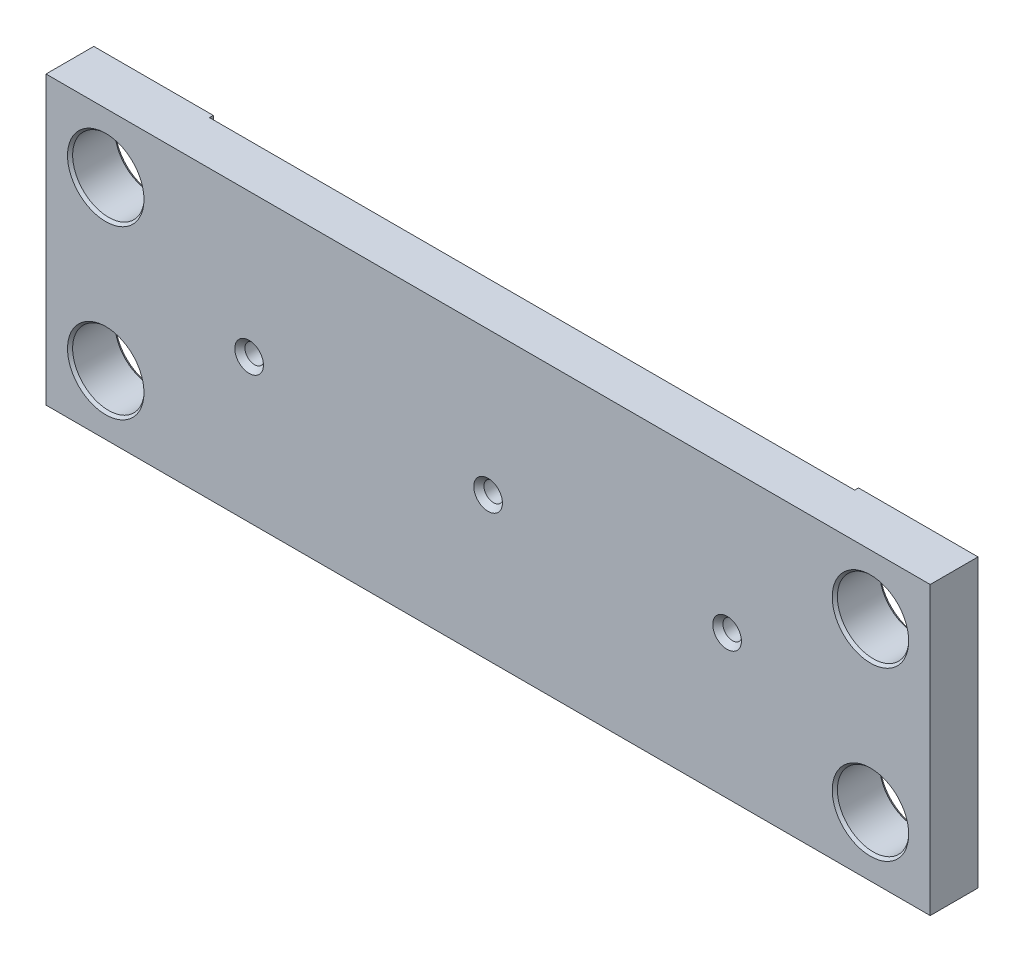
from build123d import *

# Parameters (mm, degrees)
SKETCH1_W                        = 234.95
SKETCH1_H                        = 76.2
EXTRUDE1_DEPTH                   = 12.7
F_1_2_CLEARANCE_HOLE1_AT_2_COUNT = 2
F_1_2_CLEARANCE_HOLE1_AT_2_PITCH = 44.45
F_1_2_CLEARANCE_HOLE1_AT_3_COUNT = 2
F_1_2_CLEARANCE_HOLE1_AT_3_PITCH = 203.2
F_1_2_CLEARANCE_HOLE1_AT_4_COUNT = 2
F_1_2_CLEARANCE_HOLE1_AT_4_PITCH = 208.004909798
SKETCH6_W                        = 171.45
SKETCH6_H                        = 76.2
CUT_EXTRUDE1_DEPTH               = 1.016
F_1_4_20_TAPPED_HOLE1_AT_2_COUNT = 2
F_1_4_20_TAPPED_HOLE1_AT_2_PITCH = 63.5
F_1_4_20_TAPPED_HOLE1_AT_3_COUNT = 2
F_1_4_20_TAPPED_HOLE1_AT_3_PITCH = 127


with BuildPart() as part:
    # Sketch1 → Extrude1 (new body)
    with BuildSketch(Plane.XY):
        Rectangle(SKETCH1_W, SKETCH1_H)
    extrude(amount=EXTRUDE1_DEPTH)

    # Sketch2 → 1/2 Clearance Hole1 (revolve, cut)
    with BuildSketch(Plane(origin=(-101.6, 22.225, 12.7), x_dir=(0, -1, 0), z_dir=(1, 0, 0))):
        Polygon((0, 0), (0, 12.7), (10.16, 12.7), (9.525, 11.969516061), (9.525, 0.730483939), (10.16, 0), align=None)
    f_1_2_clearance_hole1 = revolve(axis=Axis((-101.6, 22.225, 19.05), (0, 0, -1)), mode=Mode.SUBTRACT)

    # 1/2 Clearance Hole1 at 2: 1/2 Clearance Hole1 ×2
    with Locations(*[(0, -i * F_1_2_CLEARANCE_HOLE1_AT_2_PITCH, 0) for i in range(1, F_1_2_CLEARANCE_HOLE1_AT_2_COUNT)]):
        add(f_1_2_clearance_hole1, mode=Mode.SUBTRACT)

    # 1/2 Clearance Hole1 at 3: 1/2 Clearance Hole1 ×2
    with Locations(*[(i * F_1_2_CLEARANCE_HOLE1_AT_3_PITCH, 0, 0) for i in range(1, F_1_2_CLEARANCE_HOLE1_AT_3_COUNT)]):
        add(f_1_2_clearance_hole1, mode=Mode.SUBTRACT)

    # 1/2 Clearance Hole1 at 4: 1/2 Clearance Hole1 ×2
    with Locations(*[Vector(0.976900017, -0.213696879, 0) * (i * F_1_2_CLEARANCE_HOLE1_AT_4_PITCH) for i in range(1, F_1_2_CLEARANCE_HOLE1_AT_4_COUNT)]):
        add(f_1_2_clearance_hole1, mode=Mode.SUBTRACT)

    # Sketch6 → Cut-Extrude1 (cut)
    with BuildSketch(Plane(origin=(0, 0, 0), x_dir=(-1, 0, 0), z_dir=(0, 0, -1))):
        Rectangle(SKETCH6_W, SKETCH6_H)
    extrude(amount=-CUT_EXTRUDE1_DEPTH, mode=Mode.SUBTRACT)

    # Sketch4 → 1/4-20 Tapped Hole1 (revolve, cut)
    with BuildSketch(Plane(origin=(-63.5, 0, 12.7), x_dir=(0, -1, 0), z_dir=(1, 0, 0))):
        Polygon((0, 0), (0, 11.684), (3.81, 11.684), (2.5527, 10.237641802), (2.5527, 1.446358198), (3.81, 0), align=None)
    f_1_4_20_tapped_hole1 = revolve(axis=Axis((-63.5, 0, 19.05), (0, 0, -1)), mode=Mode.SUBTRACT)

    # 1/4-20 Tapped Hole1 at 2: 1/4-20 Tapped Hole1 ×2
    with Locations(*[(i * F_1_4_20_TAPPED_HOLE1_AT_2_PITCH, 0, 0) for i in range(1, F_1_4_20_TAPPED_HOLE1_AT_2_COUNT)]):
        add(f_1_4_20_tapped_hole1, mode=Mode.SUBTRACT)

    # 1/4-20 Tapped Hole1 at 3: 1/4-20 Tapped Hole1 ×2
    with Locations(*[(i * F_1_4_20_TAPPED_HOLE1_AT_3_PITCH, 0, 0) for i in range(1, F_1_4_20_TAPPED_HOLE1_AT_3_COUNT)]):
        add(f_1_4_20_tapped_hole1, mode=Mode.SUBTRACT)


solid = part.part
